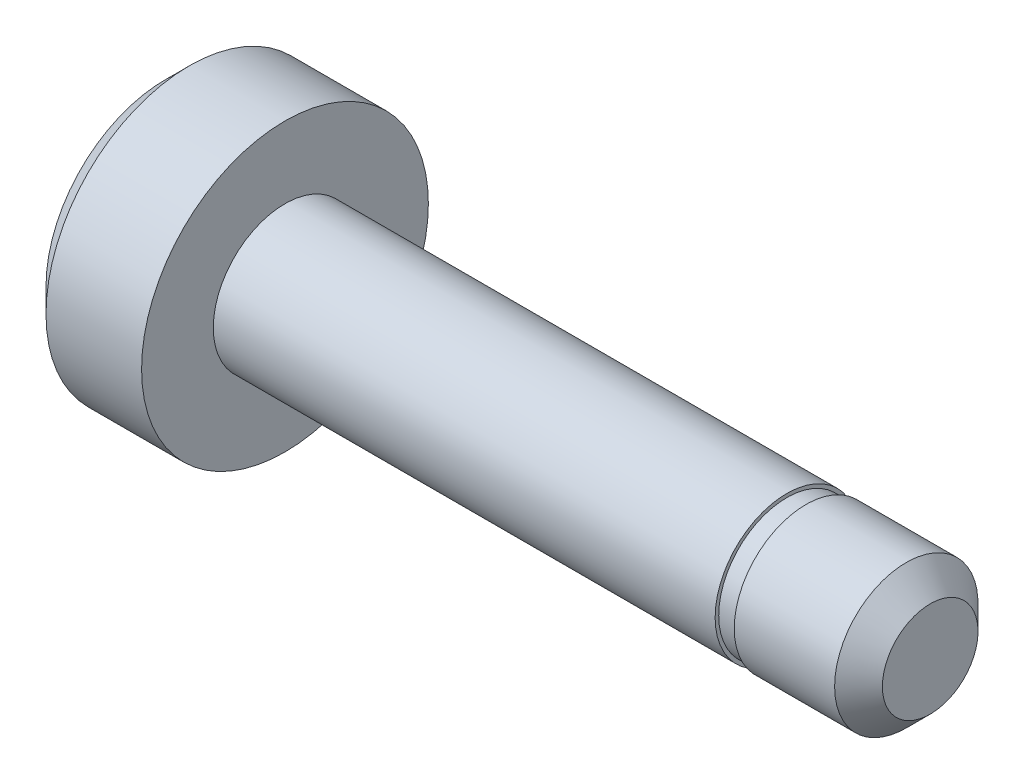
from build123d import *


with BuildPart() as part:
    # Esquisse1 → Révolution1 (revolve)
    with BuildSketch(Plane.XY):
        Polygon((0, 3), (0, 6), (-4, 6), (-5, 5), (-5, 0), (27, 0), (27, 2), (26, 3), (21.8, 3), (21.8, 2.85), (21, 2.85), (21, 3), align=None)
    revolve(axis=Axis((-27.093889619, 0, 0), (1, 0, 0)))


solid = part.part
